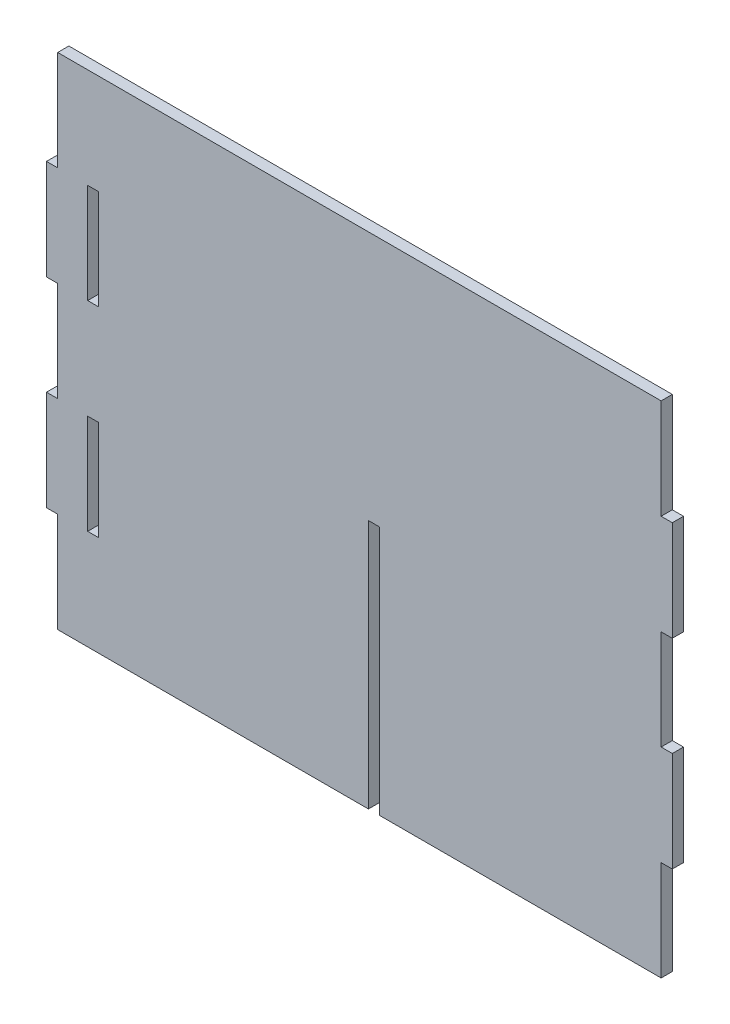
from build123d import *

# Parameters (mm, degrees)
SKETCH1_W           = 5.4
SKETCH1_H           = 48.265
BOSS_EXTRUDE1_DEPTH = 5.4
SKETCH2_W           = 5.31872
SKETCH2_H           = 48.18372
BOSS_EXTRUDE2_DEPTH = 5.4


with BuildPart() as part:
    # Sketch1 → Boss-Extrude1 (new body)
    with BuildSketch(Plane.XY):
        Polygon((9.7125, -120.6625), (145.6875, -120.6625), (145.6875, -72.3975), (151.0875, -72.3975), (151.0875, -24.1325), (145.6875, -24.1325), (145.6875, 24.1325), (151.0875, 24.1325), (151.0875, 72.3975), (145.6875, 72.3975), (145.6875, 120.6625), (-145.6875, 120.6625), (-145.6875, 72.3975), (-151.0875, 72.3975), (-151.0875, 24.1325), (-145.6875, 24.1325), (-145.6875, -24.1325), (-151.0875, -24.1325), (-151.0875, -72.3975), (-145.6875, -72.3975), (-145.6875, -120.6625), (4.3125, -120.6625), (4.3125, 0), (9.7125, 0), align=None)
        with Locations((-128.5875, -48.265)):
            Rectangle(SKETCH1_W, SKETCH1_H, mode=Mode.SUBTRACT)
        with Locations((-128.5875, 48.265)):
            Rectangle(SKETCH1_W, SKETCH1_H, mode=Mode.SUBTRACT)
    extrude(amount=BOSS_EXTRUDE1_DEPTH)

    # Sketch2 → Boss-Extrude2 (add)
    with BuildSketch(Plane.XY.offset(5.4)):
        Polygon((-145.72814, -120.70314), (4.35314, -120.70314), (4.35314, -0.04064), (9.67186, -0.04064), (9.67186, -120.70314), (145.72814, -120.70314), (145.72814, -72.43814), (151.12814, -72.43814), (151.12814, -24.09186), (145.72814, -24.09186), (145.72814, 24.09186), (151.12814, 24.09186), (151.12814, 72.43814), (145.72814, 72.43814), (145.72814, 120.70314), (-145.72814, 120.70314), (-145.72814, 72.43814), (-151.12814, 72.43814), (-151.12814, 24.09186), (-145.72814, 24.09186), (-145.72814, -24.09186), (-151.12814, -24.09186), (-151.12814, -72.43814), (-145.72814, -72.43814), align=None)
        with Locations((-128.5875, 48.265)):
            Rectangle(SKETCH2_W, SKETCH2_H, mode=Mode.SUBTRACT)
        with Locations((-128.5875, -48.265)):
            Rectangle(SKETCH2_W, SKETCH2_H, mode=Mode.SUBTRACT)
    extrude(amount=-BOSS_EXTRUDE2_DEPTH)


solid = part.part
